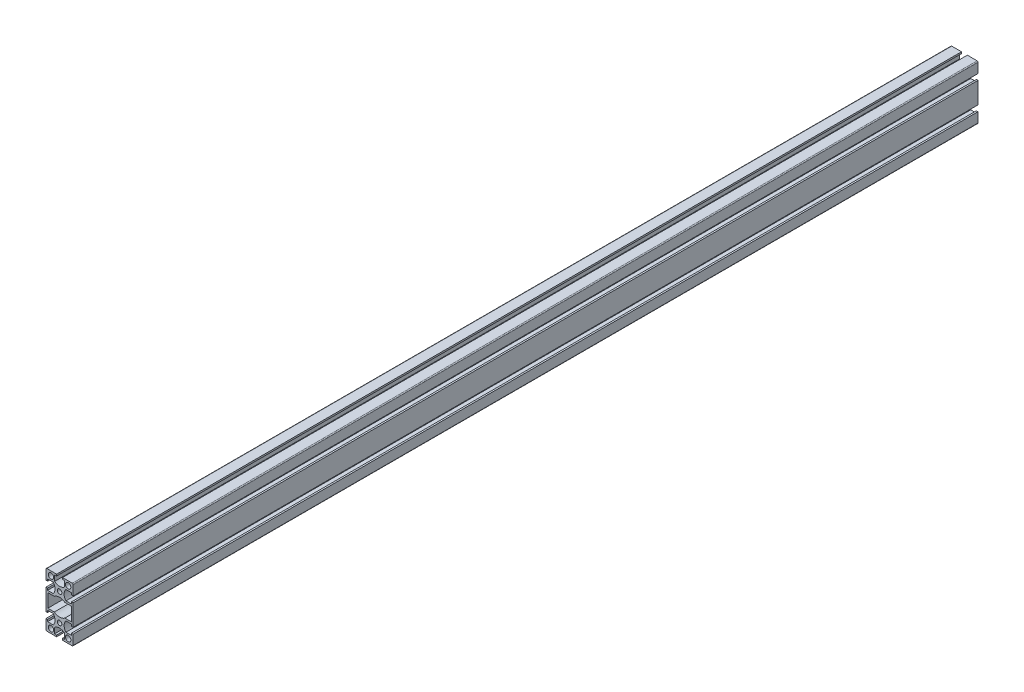
from build123d import *

# Parameters (mm, degrees)
SKETCH_1_R      = 2.5
SKETCH_1_R_2    = 3
EXTRUDE_1_DEPTH = 1000


with BuildPart() as part:
    # Эскиз1 → Бобышка-Вытянуть1 (new body)
    with BuildSketch(Plane.XY):
        with BuildLine():
            Line((-15, 5.45), (-15, 14))
            ThreePointArc((-15, 14), (-14.707106781, 14.707106781), (-14, 15))
            Line((-14, 15), (-5.45, 15))
            Line((-5.45, 15), (-3.25, 15))
            Line((-3.25, 15), (-3.25, 13.2))
            Line((-3.25, 13.2), (-5.45, 13.2))
            Line((-5.45, 13.2), (-5.45, 7))
            ThreePointArc((-5.45, 7), (0, 5.022844472), (5.45, 7))
            Line((5.45, 7), (5.45, 13.2))
            Line((5.45, 13.2), (3.25, 13.2))
            Line((3.25, 13.2), (3.25, 15))
            Line((3.25, 15), (5.45, 15))
            Line((5.45, 15), (14, 15))
            ThreePointArc((14, 15), (14.707106781, 14.707106781), (15, 14))
            Line((15, 14), (15, 5.45))
            Line((15, 5.45), (15, 3.25))
            Line((15, 3.25), (13.2, 3.25))
            Line((13.2, 3.25), (13.2, 5.45))
            Line((13.2, 5.45), (7, 5.45))
            ThreePointArc((7, 5.45), (5.022844472, 0), (7, -5.45))
            Line((7, -5.45), (13.2, -5.45))
            Line((13.2, -5.45), (13.2, -3.25))
            Line((13.2, -3.25), (15, -3.25))
            Line((15, -3.25), (15, -5.45))
            Line((15, -5.45), (15, -24.55))
            Line((15, -24.55), (15, -26.75))
            Line((15, -26.75), (13.2, -26.75))
            Line((13.2, -26.75), (13.2, -24.55))
            Line((13.2, -24.55), (7, -24.55))
            ThreePointArc((7, -24.55), (5.022844472, -30), (7, -35.45))
            Line((7, -35.45), (13.2, -35.45))
            Line((13.2, -35.45), (13.2, -33.25))
            Line((13.2, -33.25), (15, -33.25))
            Line((15, -33.25), (15, -35.45))
            Line((15, -35.45), (15, -44))
            ThreePointArc((15, -44), (14.707106781, -44.707106781), (14, -45))
            Line((14, -45), (5.45, -45))
            Line((5.45, -45), (3.25, -45))
            Line((3.25, -45), (3.25, -43.2))
            Line((3.25, -43.2), (5.45, -43.2))
            Line((5.45, -43.2), (5.45, -37))
            ThreePointArc((5.45, -37), (0, -35.022844472), (-5.45, -37))
            Line((-5.45, -37), (-5.45, -43.2))
            Line((-5.45, -43.2), (-3.25, -43.2))
            Line((-3.25, -43.2), (-3.25, -45))
            Line((-3.25, -45), (-5.45, -45))
            Line((-5.45, -45), (-14, -45))
            ThreePointArc((-14, -45), (-14.707106781, -44.707106781), (-15, -44))
            Line((-15, -44), (-15, -35.45))
            Line((-15, -35.45), (-15, -33.25))
            Line((-15, -33.25), (-13.2, -33.25))
            Line((-13.2, -33.25), (-13.2, -35.45))
            Line((-13.2, -35.45), (-7, -35.45))
            ThreePointArc((-7, -35.45), (-5.022844472, -30), (-7, -24.55))
            Line((-7, -24.55), (-13.2, -24.55))
            Line((-13.2, -24.55), (-13.2, -26.75))
            Line((-13.2, -26.75), (-15, -26.75))
            Line((-15, -26.75), (-15, -24.55))
            Line((-15, -24.55), (-15, -5.45))
            Line((-15, -5.45), (-15, -3.25))
            Line((-15, -3.25), (-13.2, -3.25))
            Line((-13.2, -3.25), (-13.2, -5.45))
            Line((-13.2, -5.45), (-7, -5.45))
            ThreePointArc((-7, -5.45), (-5.022844472, 0), (-7, 5.45))
            Line((-7, 5.45), (-13.2, 5.45))
            Line((-13.2, 5.45), (-13.2, 3.25))
            Line((-13.2, 3.25), (-15, 3.25))
            Line((-15, 3.25), (-15, 5.45))
        make_face()
        Circle(SKETCH_1_R, mode=Mode.SUBTRACT)
        with Locations((0, -30)):
            Circle(SKETCH_1_R, mode=Mode.SUBTRACT)
        with Locations((-9.5, 10.25)):
            Circle(SKETCH_1_R_2, mode=Mode.SUBTRACT)
        with Locations((9.5, 10.25)):
            Circle(SKETCH_1_R_2, mode=Mode.SUBTRACT)
        with Locations((-9.5, -40.25)):
            Circle(SKETCH_1_R_2, mode=Mode.SUBTRACT)
        with Locations((9.5, -40.25)):
            Circle(SKETCH_1_R_2, mode=Mode.SUBTRACT)
        with BuildLine():
            Line((-13, -22.5), (-13, -7.5))
            Line((-13, -7.5), (-5.830951895, -7.5))
            ThreePointArc((-5.830951895, -7.5), (0, -5.5), (5.830951895, -7.5))
            Line((5.830951895, -7.5), (13, -7.5))
            Line((13, -7.5), (13, -22.5))
            Line((13, -22.5), (5.830951895, -22.5))
            ThreePointArc((5.830951895, -22.5), (0, -24.5), (-5.830951895, -22.5))
            Line((-5.830951895, -22.5), (-13, -22.5))
        make_face(mode=Mode.SUBTRACT)
    extrude(amount=EXTRUDE_1_DEPTH)


solid = part.part
